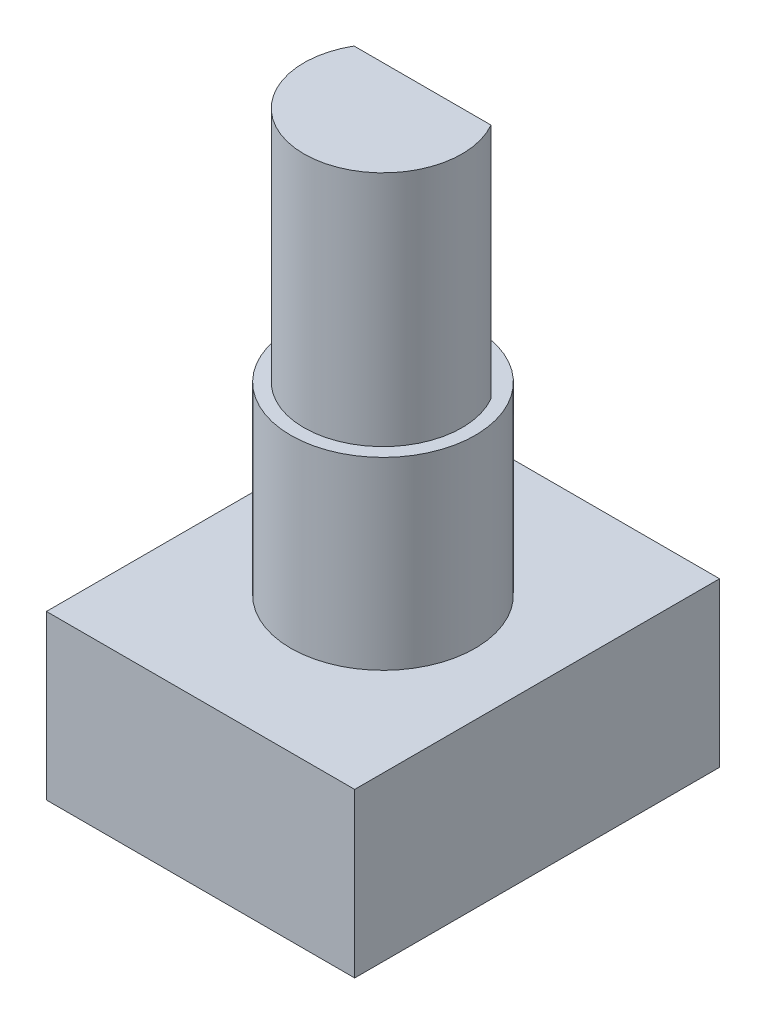
from build123d import *

# Parameters (mm, degrees)
SKETCH1_W           = 11.7
SKETCH1_H           = 13.85
BOSS_EXTRUDE1_DEPTH = 6.2
SKETCH2_R           = 3.5
BOSS_EXTRUDE2_DEPTH = 7
BOSS_EXTRUDE3_DEPTH = 9


with BuildPart() as part:
    # Sketch1 → Boss-Extrude1 (new body)
    with BuildSketch(Plane(origin=(0, 0, 0), x_dir=(1, 0, 0), z_dir=(0, 1, 0))):
        with Locations((5.85, 6.925)):
            Rectangle(SKETCH1_W, SKETCH1_H)
    extrude(amount=BOSS_EXTRUDE1_DEPTH)

    # Sketch2 → Boss-Extrude2 (add)
    with BuildSketch(Plane(origin=(0, 6.2, 0), x_dir=(1, 0, 0), z_dir=(0, 1, 0))):
        with Locations((5.85, 6.925)):
            Circle(SKETCH2_R)
    extrude(amount=BOSS_EXTRUDE2_DEPTH)

    # Sketch3 → Boss-Extrude3 (add)
    with BuildSketch(Plane(origin=(0, 13.2, 0), x_dir=(1, 0, 0), z_dir=(0, 1, 0))):
        with BuildLine():
            Line((3.251923789, 8.425), (8.448076211, 8.425))
            ThreePointArc((8.448076211, 8.425), (5.85, 3.925), (3.251923789, 8.425))
        make_face()
    extrude(amount=BOSS_EXTRUDE3_DEPTH)


solid = part.part
